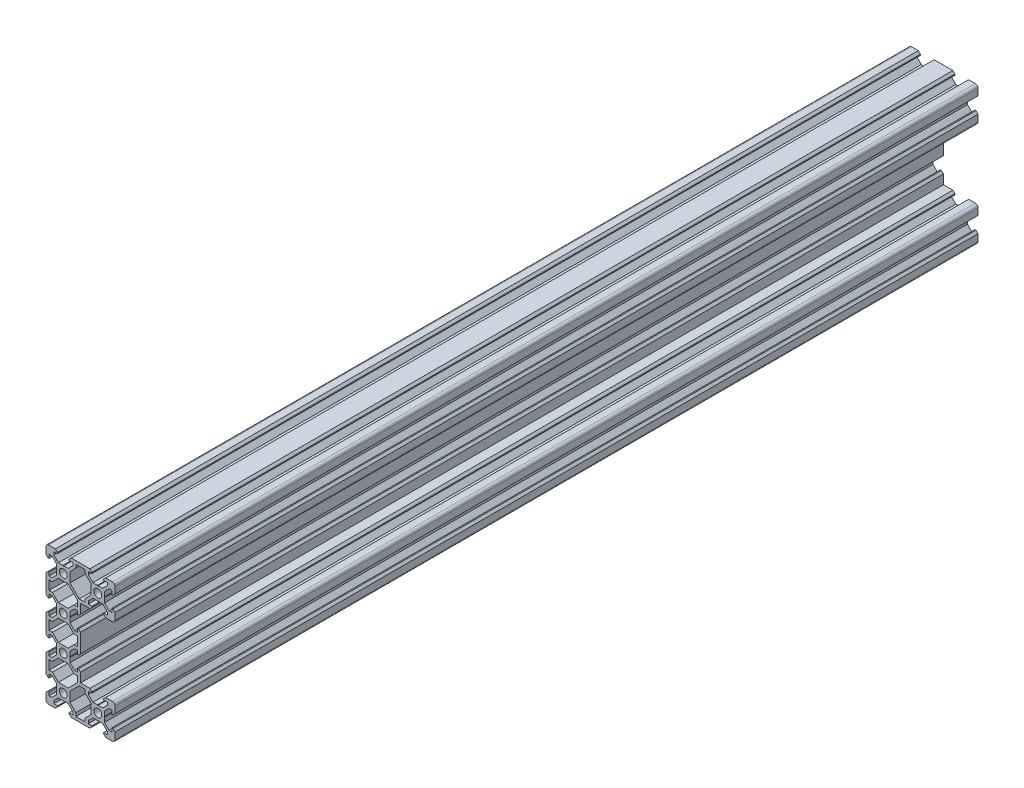
from build123d import *

# Parameters (mm, degrees)
SKETCH1_R           = 2.3
BOSS_EXTRUDE1_DEPTH = 500


with BuildPart() as part:
    # Sketch1 → Boss-Extrude1 (new body)
    with BuildSketch(Plane.XY):
        with BuildLine():
            Line((-20, -34.58), (-20, -38.5))
            ThreePointArc((-20, -38.5), (-19.560660172, -39.560660172), (-18.5, -40))
            Line((-18.5, -40), (-14.58, -40))
            Line((-14.58, -40), (-13.395, -38.815))
            Line((-13.395, -38.815), (-13.395, -38.2))
            Line((-13.395, -38.2), (-15.5, -38.2))
            Line((-15.5, -38.2), (-15.5, -36.560660172))
            Line((-15.5, -36.560660172), (-12.839339828, -33.9))
            Line((-12.839339828, -33.9), (-10.21, -33.9))
            Line((-10.21, -33.9), (-10, -33.69))
            Line((-10, -33.69), (-9.79, -33.9))
            Line((-9.79, -33.9), (-7.160660172, -33.9))
            Line((-7.160660172, -33.9), (-4.5, -36.560660172))
            Line((-4.5, -36.560660172), (-4.5, -38.2))
            Line((-4.5, -38.2), (-6.605, -38.2))
            Line((-6.605, -38.2), (-6.605, -38.815))
            Line((-6.605, -38.815), (-5.42, -40))
            Line((-5.42, -40), (5.42, -40))
            Line((5.42, -40), (6.605, -38.815))
            Line((6.605, -38.815), (6.605, -38.2))
            Line((6.605, -38.2), (4.5, -38.2))
            Line((4.5, -38.2), (4.5, -36.560660172))
            Line((4.5, -36.560660172), (7.160660172, -33.9))
            Line((7.160660172, -33.9), (9.79, -33.9))
            Line((9.79, -33.9), (10, -33.69))
            Line((10, -33.69), (10.21, -33.9))
            Line((10.21, -33.9), (12.839339828, -33.9))
            Line((12.839339828, -33.9), (15.5, -36.560660172))
            Line((15.5, -36.560660172), (15.5, -38.2))
            Line((15.5, -38.2), (13.395, -38.2))
            Line((13.395, -38.2), (13.395, -38.815))
            Line((13.395, -38.815), (14.58, -40))
            Line((14.58, -40), (18.5, -40))
            ThreePointArc((18.5, -40), (19.560660172, -39.560660172), (20, -38.5))
            Line((20, -38.5), (20, -34.58))
            Line((20, -34.58), (18.815, -33.395))
            Line((18.815, -33.395), (18.2, -33.395))
            Line((18.2, -33.395), (18.2, -35.5))
            Line((18.2, -35.5), (16.560660172, -35.5))
            Line((16.560660172, -35.5), (13.9, -32.839339828))
            Line((13.9, -32.839339828), (13.9, -30.21))
            Line((13.9, -30.21), (13.69, -30))
            Line((13.69, -30), (13.9, -29.79))
            Line((13.9, -29.79), (13.9, -27.160660172))
            Line((13.9, -27.160660172), (16.560660172, -24.5))
            Line((16.560660172, -24.5), (18.2, -24.5))
            Line((18.2, -24.5), (18.2, -26.605))
            Line((18.2, -26.605), (18.815, -26.605))
            Line((18.815, -26.605), (20, -25.42))
            Line((20, -25.42), (20, -21.5))
            ThreePointArc((20, -21.5), (19.560660172, -20.439339828), (18.5, -20))
            Line((18.5, -20), (14.58, -20))
            Line((14.58, -20), (13.395, -21.185))
            Line((13.395, -21.185), (13.395, -21.8))
            Line((13.395, -21.8), (15.5, -21.8))
            Line((15.5, -21.8), (15.5, -23.439339828))
            Line((15.5, -23.439339828), (12.839339828, -26.1))
            Line((12.839339828, -26.1), (10.21, -26.1))
            Line((10.21, -26.1), (10, -26.31))
            Line((10, -26.31), (9.79, -26.1))
            Line((9.79, -26.1), (7.160660172, -26.1))
            Line((7.160660172, -26.1), (4.5, -23.439339828))
            Line((4.5, -23.439339828), (4.5, -21.8))
            Line((4.5, -21.8), (6.605, -21.8))
            Line((6.605, -21.8), (6.605, -21.185))
            Line((6.605, -21.185), (5.42, -20))
            Line((5.42, -20), (0, -20))
            Line((0, -20), (0, -14.58))
            Line((0, -14.58), (-1.185, -13.395))
            Line((-1.185, -13.395), (-1.8, -13.395))
            Line((-1.8, -13.395), (-1.8, -15.5))
            Line((-1.8, -15.5), (-3.439339828, -15.5))
            Line((-3.439339828, -15.5), (-6.1, -12.839339828))
            Line((-6.1, -12.839339828), (-6.1, -10.21))
            Line((-6.1, -10.21), (-6.31, -10))
            Line((-6.31, -10), (-6.1, -9.79))
            Line((-6.1, -9.79), (-6.1, -7.160660172))
            Line((-6.1, -7.160660172), (-3.439339828, -4.5))
            Line((-3.439339828, -4.5), (-1.8, -4.5))
            Line((-1.8, -4.5), (-1.8, -6.605))
            Line((-1.8, -6.605), (-1.185, -6.605))
            Line((-1.185, -6.605), (0, -5.42))
            Line((0, -5.42), (0, 5.42))
            Line((0, 5.42), (-1.185, 6.605))
            Line((-1.185, 6.605), (-1.8, 6.605))
            Line((-1.8, 6.605), (-1.8, 4.5))
            Line((-1.8, 4.5), (-3.439339828, 4.5))
            Line((-3.439339828, 4.5), (-6.1, 7.160660172))
            Line((-6.1, 7.160660172), (-6.1, 9.79))
            Line((-6.1, 9.79), (-6.31, 10))
            Line((-6.31, 10), (-6.1, 10.21))
            Line((-6.1, 10.21), (-6.1, 12.839339828))
            Line((-6.1, 12.839339828), (-3.439339828, 15.5))
            Line((-3.439339828, 15.5), (-1.8, 15.5))
            Line((-1.8, 15.5), (-1.8, 13.395))
            Line((-1.8, 13.395), (-1.185, 13.395))
            Line((-1.185, 13.395), (0, 14.58))
            Line((0, 14.58), (0, 20))
            Line((0, 20), (5.42, 20))
            Line((5.42, 20), (6.605, 21.185))
            Line((6.605, 21.185), (6.605, 21.8))
            Line((6.605, 21.8), (4.5, 21.8))
            Line((4.5, 21.8), (4.5, 23.439339828))
            Line((4.5, 23.439339828), (7.160660172, 26.1))
            Line((7.160660172, 26.1), (9.79, 26.1))
            Line((9.79, 26.1), (10, 26.31))
            Line((10, 26.31), (10.21, 26.1))
            Line((10.21, 26.1), (12.839339828, 26.1))
            Line((12.839339828, 26.1), (15.5, 23.439339828))
            Line((15.5, 23.439339828), (15.5, 21.8))
            Line((15.5, 21.8), (13.395, 21.8))
            Line((13.395, 21.8), (13.395, 21.185))
            Line((13.395, 21.185), (14.58, 20))
            Line((14.58, 20), (18.5, 20))
            ThreePointArc((18.5, 20), (19.560660172, 20.439339828), (20, 21.5))
            Line((20, 21.5), (20, 25.42))
            Line((20, 25.42), (18.815, 26.605))
            Line((18.815, 26.605), (18.2, 26.605))
            Line((18.2, 26.605), (18.2, 24.5))
            Line((18.2, 24.5), (16.560660172, 24.5))
            Line((16.560660172, 24.5), (13.9, 27.160660172))
            Line((13.9, 27.160660172), (13.9, 29.79))
            Line((13.9, 29.79), (13.69, 30))
            Line((13.69, 30), (13.9, 30.21))
            Line((13.9, 30.21), (13.9, 32.839339828))
            Line((13.9, 32.839339828), (16.560660172, 35.5))
            Line((16.560660172, 35.5), (18.2, 35.5))
            Line((18.2, 35.5), (18.2, 33.395))
            Line((18.2, 33.395), (18.815, 33.395))
            Line((18.815, 33.395), (20, 34.58))
            Line((20, 34.58), (20, 38.5))
            ThreePointArc((20, 38.5), (19.560660172, 39.560660172), (18.5, 40))
            Line((18.5, 40), (14.58, 40))
            Line((14.58, 40), (13.395, 38.815))
            Line((13.395, 38.815), (13.395, 38.2))
            Line((13.395, 38.2), (15.5, 38.2))
            Line((15.5, 38.2), (15.5, 36.560660172))
            Line((15.5, 36.560660172), (12.839339828, 33.9))
            Line((12.839339828, 33.9), (10.21, 33.9))
            Line((10.21, 33.9), (10, 33.69))
            Line((10, 33.69), (9.79, 33.9))
            Line((9.79, 33.9), (7.160660172, 33.9))
            Line((7.160660172, 33.9), (4.5, 36.560660172))
            Line((4.5, 36.560660172), (4.5, 38.2))
            Line((4.5, 38.2), (6.605, 38.2))
            Line((6.605, 38.2), (6.605, 38.815))
            Line((6.605, 38.815), (5.42, 40))
            Line((5.42, 40), (-5.42, 40))
            Line((-5.42, 40), (-6.605, 38.815))
            Line((-6.605, 38.815), (-6.605, 38.2))
            Line((-6.605, 38.2), (-4.5, 38.2))
            Line((-4.5, 38.2), (-4.5, 36.560660172))
            Line((-4.5, 36.560660172), (-7.160660172, 33.9))
            Line((-7.160660172, 33.9), (-9.79, 33.9))
            Line((-9.79, 33.9), (-10, 33.69))
            Line((-10, 33.69), (-10.21, 33.9))
            Line((-10.21, 33.9), (-12.839339828, 33.9))
            Line((-12.839339828, 33.9), (-15.5, 36.560660172))
            Line((-15.5, 36.560660172), (-15.5, 38.2))
            Line((-15.5, 38.2), (-13.395, 38.2))
            Line((-13.395, 38.2), (-13.395, 38.815))
            Line((-13.395, 38.815), (-14.58, 40))
            Line((-14.58, 40), (-18.5, 40))
            ThreePointArc((-18.5, 40), (-19.560660172, 39.560660172), (-20, 38.5))
            Line((-20, 38.5), (-20, 34.58))
            Line((-20, 34.58), (-18.815, 33.395))
            Line((-18.815, 33.395), (-18.2, 33.395))
            Line((-18.2, 33.395), (-18.2, 35.5))
            Line((-18.2, 35.5), (-16.560660172, 35.5))
            Line((-16.560660172, 35.5), (-13.9, 32.839339828))
            Line((-13.9, 32.839339828), (-13.9, 30.21))
            Line((-13.9, 30.21), (-13.69, 30))
            Line((-13.69, 30), (-13.9, 29.79))
            Line((-13.9, 29.79), (-13.9, 27.160660172))
            Line((-13.9, 27.160660172), (-16.560660172, 24.5))
            Line((-16.560660172, 24.5), (-18.2, 24.5))
            Line((-18.2, 24.5), (-18.2, 26.605))
            Line((-18.2, 26.605), (-18.815, 26.605))
            Line((-18.815, 26.605), (-20, 25.42))
            Line((-20, 25.42), (-20, 14.58))
            Line((-20, 14.58), (-18.815, 13.395))
            Line((-18.815, 13.395), (-18.2, 13.395))
            Line((-18.2, 13.395), (-18.2, 15.5))
            Line((-18.2, 15.5), (-16.560660172, 15.5))
            Line((-16.560660172, 15.5), (-13.9, 12.839339828))
            Line((-13.9, 12.839339828), (-13.9, 10.21))
            Line((-13.9, 10.21), (-13.69, 10))
            Line((-13.69, 10), (-13.9, 9.79))
            Line((-13.9, 9.79), (-13.9, 7.160660172))
            Line((-13.9, 7.160660172), (-16.560660172, 4.5))
            Line((-16.560660172, 4.5), (-18.2, 4.5))
            Line((-18.2, 4.5), (-18.2, 6.605))
            Line((-18.2, 6.605), (-18.815, 6.605))
            Line((-18.815, 6.605), (-20, 5.42))
            Line((-20, 5.42), (-20, -5.42))
            Line((-20, -5.42), (-18.815, -6.605))
            Line((-18.815, -6.605), (-18.2, -6.605))
            Line((-18.2, -6.605), (-18.2, -4.5))
            Line((-18.2, -4.5), (-16.560660172, -4.5))
            Line((-16.560660172, -4.5), (-13.9, -7.160660172))
            Line((-13.9, -7.160660172), (-13.9, -9.79))
            Line((-13.9, -9.79), (-13.69, -10))
            Line((-13.69, -10), (-13.9, -10.21))
            Line((-13.9, -10.21), (-13.9, -12.839339828))
            Line((-13.9, -12.839339828), (-16.560660172, -15.5))
            Line((-16.560660172, -15.5), (-18.2, -15.5))
            Line((-18.2, -15.5), (-18.2, -13.395))
            Line((-18.2, -13.395), (-18.815, -13.395))
            Line((-18.815, -13.395), (-20, -14.58))
            Line((-20, -14.58), (-20, -25.42))
            Line((-20, -25.42), (-18.815, -26.605))
            Line((-18.815, -26.605), (-18.2, -26.605))
            Line((-18.2, -26.605), (-18.2, -24.5))
            Line((-18.2, -24.5), (-16.560660172, -24.5))
            Line((-16.560660172, -24.5), (-13.9, -27.160660172))
            Line((-13.9, -27.160660172), (-13.9, -29.79))
            Line((-13.9, -29.79), (-13.69, -30))
            Line((-13.69, -30), (-13.9, -30.21))
            Line((-13.9, -30.21), (-13.9, -32.839339828))
            Line((-13.9, -32.839339828), (-16.560660172, -35.5))
            Line((-16.560660172, -35.5), (-18.2, -35.5))
            Line((-18.2, -35.5), (-18.2, -33.395))
            Line((-18.2, -33.395), (-18.815, -33.395))
            Line((-18.815, -33.395), (-20, -34.58))
        make_face()
        with Locations((-10, -30)):
            Circle(SKETCH1_R, mode=Mode.SUBTRACT)
        Polygon((-16.239339828, -22.7), (-18.2, -22.7), (-18.2, -17.3), (-16.239339828, -17.3), (-12.839339828, -13.9), (-7.160660172, -13.9), (-3.760660172, -17.3), (-1.8, -17.3), (-1.8, -20.739339828), (-7.160660172, -26.1), (-12.839339828, -26.1), align=None, mode=Mode.SUBTRACT)
        with Locations((-10, -10)):
            Circle(SKETCH1_R, mode=Mode.SUBTRACT)
        Polygon((2.7, -36.239339828), (2.7, -38.2), (-2.7, -38.2), (-2.7, -36.239339828), (-6.1, -32.839339828), (-6.1, -27.160660172), (-0.739339828, -21.8), (2.7, -21.8), (2.7, -23.760660172), (6.1, -27.160660172), (6.1, -32.839339828), align=None, mode=Mode.SUBTRACT)
        with Locations((10, -30)):
            Circle(SKETCH1_R, mode=Mode.SUBTRACT)
        Polygon((-16.239339828, -2.7), (-18.2, -2.7), (-18.2, 2.7), (-16.239339828, 2.7), (-12.839339828, 6.1), (-7.160660172, 6.1), (-3.760660172, 2.7), (-1.8, 2.7), (-1.8, -2.7), (-3.760660172, -2.7), (-7.160660172, -6.1), (-12.839339828, -6.1), align=None, mode=Mode.SUBTRACT)
        with Locations((-10, 10)):
            Circle(SKETCH1_R, mode=Mode.SUBTRACT)
        Polygon((-16.239339828, 17.3), (-18.2, 17.3), (-18.2, 22.7), (-16.239339828, 22.7), (-12.839339828, 26.1), (-7.160660172, 26.1), (-1.8, 20.739339828), (-1.8, 17.3), (-3.760660172, 17.3), (-7.160660172, 13.9), (-12.839339828, 13.9), align=None, mode=Mode.SUBTRACT)
        with Locations((-10, 30)):
            Circle(SKETCH1_R, mode=Mode.SUBTRACT)
        Polygon((-2.7, 36.239339828), (-2.7, 38.2), (2.7, 38.2), (2.7, 36.239339828), (6.1, 32.839339828), (6.1, 27.160660172), (2.7, 23.760660172), (2.7, 21.8), (-0.739339828, 21.8), (-6.1, 27.160660172), (-6.1, 32.839339828), align=None, mode=Mode.SUBTRACT)
        with Locations((10, 30)):
            Circle(SKETCH1_R, mode=Mode.SUBTRACT)
    extrude(amount=BOSS_EXTRUDE1_DEPTH)


solid = part.part
